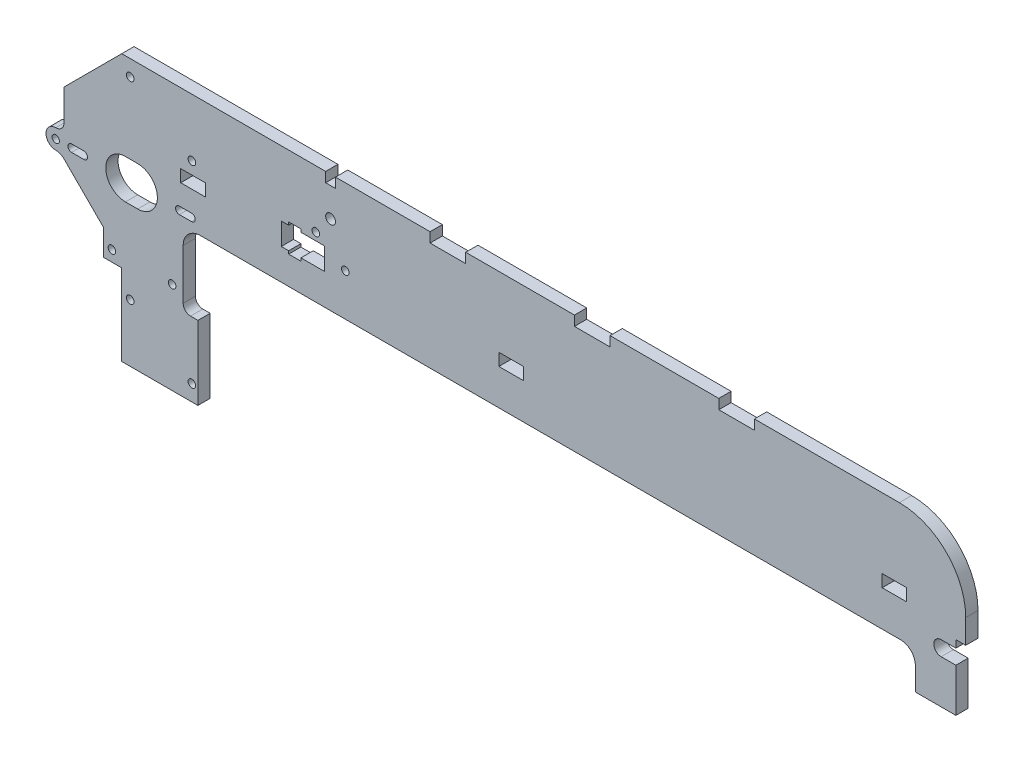
from build123d import *

# Parameters (mm, degrees)
SKETCH1_R           = 1.5
SKETCH1_R_2         = 8
SKETCH1_R_3         = 1.55
SKETCH1_R_4         = 2
SKETCH1_W           = 10
SKETCH1_H           = 5
BOSS_EXTRUDE1_DEPTH = 5
FILLET2_R           = 7
FILLET3_R           = 3
CUT_EXTRUDE1_DEPTH  = 6
FILLET4_R           = 6


with BuildPart() as part:
    # Sketch1 → Boss-Extrude1 (new body)
    with BuildSketch(Plane.XY):
        with BuildLine():
            Line((310, 43.5), (251, 43.5))
            Line((251, 43.5), (251, 39.5))
            Line((251, 39.5), (236.5, 39.5))
            Line((236.5, 39.5), (236.5, 43.5))
            Line((236.5, 43.5), (192.25, 43.5))
            Line((192.25, 43.5), (192.25, 39.5))
            Line((192.25, 39.5), (177.75, 39.5))
            Line((177.75, 39.5), (177.75, 43.5))
            Line((177.75, 43.5), (133.5, 43.5))
            Line((133.5, 43.5), (133.5, 39.5))
            Line((133.5, 39.5), (119, 39.5))
            Line((119, 39.5), (119, 43.5))
            Line((119, 43.5), (80.5, 43.5))
            Line((80.5, 43.5), (80.5, 39.5))
            Line((80.5, 39.5), (76.5, 39.5))
            Line((76.5, 39.5), (76.5, 43.5))
            Line((76.5, 43.5), (-6.5, 43.5))
            Line((-6.5, 43.5), (-30, 20))
            Line((-30, 20), (-30, 7.325414703))
            ThreePointArc((-30, 7.325414703), (-30.985037822, 4.947323034), (-33.36312949, 3.962285212))
            ThreePointArc((-33.36312949, 3.962285212), (-37.325414703, 0), (-33.36312949, -3.962285212))
            ThreePointArc((-33.36312949, -3.962285212), (-31.543016926, -4.324328111), (-30, -5.355339059))
            Line((-30, -5.355339059), (-14, -21.355339059))
            Line((-14, -21.355339059), (-14, -32))
            Line((-14, -32), (-6.5, -32))
            Line((-6.5, -32), (-6.5, -65))
            Line((-6.5, -65), (24.5, -65))
            Line((24.5, -65), (24.5, -35))
            Line((24.5, -35), (18.5, -35))
            Line((18.5, -35), (18.5, -4.6))
            Line((18.5, -4.6), (316.5, -4.6))
            Line((316.5, -4.6), (316.5, -20))
            Line((316.5, -20), (333, -20))
            Line((333, -20), (333, -2.3))
            Line((333, -2.3), (327, -2.3))
            ThreePointArc((327, -2.3), (324, 0.7), (327, 3.7))
            Line((327, 3.7), (333, 3.7))
            Line((333, 3.7), (333, 6.7))
            Line((333, 6.7), (337, 6.7))
            Line((337, 6.7), (337, 16.5))
            ThreePointArc((337, 16.5), (329.091883092, 35.591883092), (310, 43.5))
        make_face()
        with Locations((21.920310217, 0)):
            Circle(SKETCH1_R, mode=Mode.SUBTRACT)
        with Locations((-21.920310217, 0)):
            Circle(SKETCH1_R, mode=Mode.SUBTRACT)
        Circle(SKETCH1_R_2, mode=Mode.SUBTRACT)
        with Locations((-3.05, 37)):
            Circle(SKETCH1_R_3, mode=Mode.SUBTRACT)
        with Locations((22.05, 20)):
            Circle(SKETCH1_R_3, mode=Mode.SUBTRACT)
        with Locations((-3.05, -41.5)):
            Circle(SKETCH1_R_3, mode=Mode.SUBTRACT)
        with Locations((22.05, -58.5)):
            Circle(SKETCH1_R_3, mode=Mode.SUBTRACT)
        with Locations((72.5, 20.1)):
            Circle(SKETCH1_R_3, mode=Mode.SUBTRACT)
        with Locations((84.5, 12.5)):
            Circle(SKETCH1_R_3, mode=Mode.SUBTRACT)
        with Locations((-10.5, -27.55)):
            Circle(SKETCH1_R_3, mode=Mode.SUBTRACT)
        with Locations((14, -27.55)):
            Circle(SKETCH1_R_3, mode=Mode.SUBTRACT)
        with Locations((-33.36312949, 0)):
            Circle(SKETCH1_R, mode=Mode.SUBTRACT)
        with Locations((78.5, 27.751425951)):
            Circle(SKETCH1_R_4, mode=Mode.SUBTRACT)
        with Locations((22.5, 12.5)):
            Rectangle(SKETCH1_W, SKETCH1_H, mode=Mode.SUBTRACT)
        with Locations((152, 12.5)):
            Rectangle(SKETCH1_W, SKETCH1_H, mode=Mode.SUBTRACT)
        with Locations((308, 12.5)):
            Rectangle(SKETCH1_W, SKETCH1_H, mode=Mode.SUBTRACT)
        Polygon((58.427680349, 8), (61.427680349, 8), (61.427680349, 6.806102344), (66.427680349, 6.806102344), (66.427680349, 8), (76, 8), (76, 17), (66.427680349, 17), (66.427680349, 18.193897656), (61.427680349, 18.193897656), (61.427680349, 17), (58.427680349, 17), align=None, mode=Mode.SUBTRACT)
    extrude(amount=BOSS_EXTRUDE1_DEPTH)

    # Fillet2
    fillet2_edges = [part.edges().sort_by_distance(p)[0] for p in [
        (18.5, -4.6, 2.5),
    ]]
    fillet(fillet2_edges, radius=FILLET2_R)

    # Fillet3
    fillet3_edges = [part.edges().sort_by_distance(p)[0] for p in [
        (18.5, -35, 2.5),
    ]]
    fillet(fillet3_edges, radius=FILLET3_R)

    # Sketch2 → Cut-Extrude1 (cut, through all)
    with BuildSketch(Plane.XY.offset(5)):
        with BuildLine():
            Line((21.920310217, -1.5), (16.920310217, -1.5))
            ThreePointArc((16.920310217, -1.5), (15.420310217, 0), (16.920310217, 1.5))
            Line((16.920310217, 1.5), (21.920310217, 1.5))
            ThreePointArc((21.920310217, 1.5), (23.420310217, 0), (21.920310217, -1.5))
        make_face()
        with BuildLine():
            Line((0, -8), (-5, -8))
            ThreePointArc((-5, -8), (-13, 0), (-5, 8))
            Line((-5, 8), (0, 8))
            ThreePointArc((0, 8), (8, 0), (0, -8))
        make_face()
        with BuildLine():
            Line((-21.920310217, -1.5), (-26.920310217, -1.5))
            ThreePointArc((-26.920310217, -1.5), (-28.420310217, 0), (-26.920310217, 1.5))
            Line((-26.920310217, 1.5), (-21.920310217, 1.5))
            ThreePointArc((-21.920310217, 1.5), (-20.420310217, 0), (-21.920310217, -1.5))
        make_face()
    extrude(amount=-CUT_EXTRUDE1_DEPTH, mode=Mode.SUBTRACT)

    # Fillet4
    fillet4_edges = [part.edges().sort_by_distance(p)[0] for p in [
        (316.5, -4.6, 2.5),
    ]]
    fillet(fillet4_edges, radius=FILLET4_R)


solid = part.part
